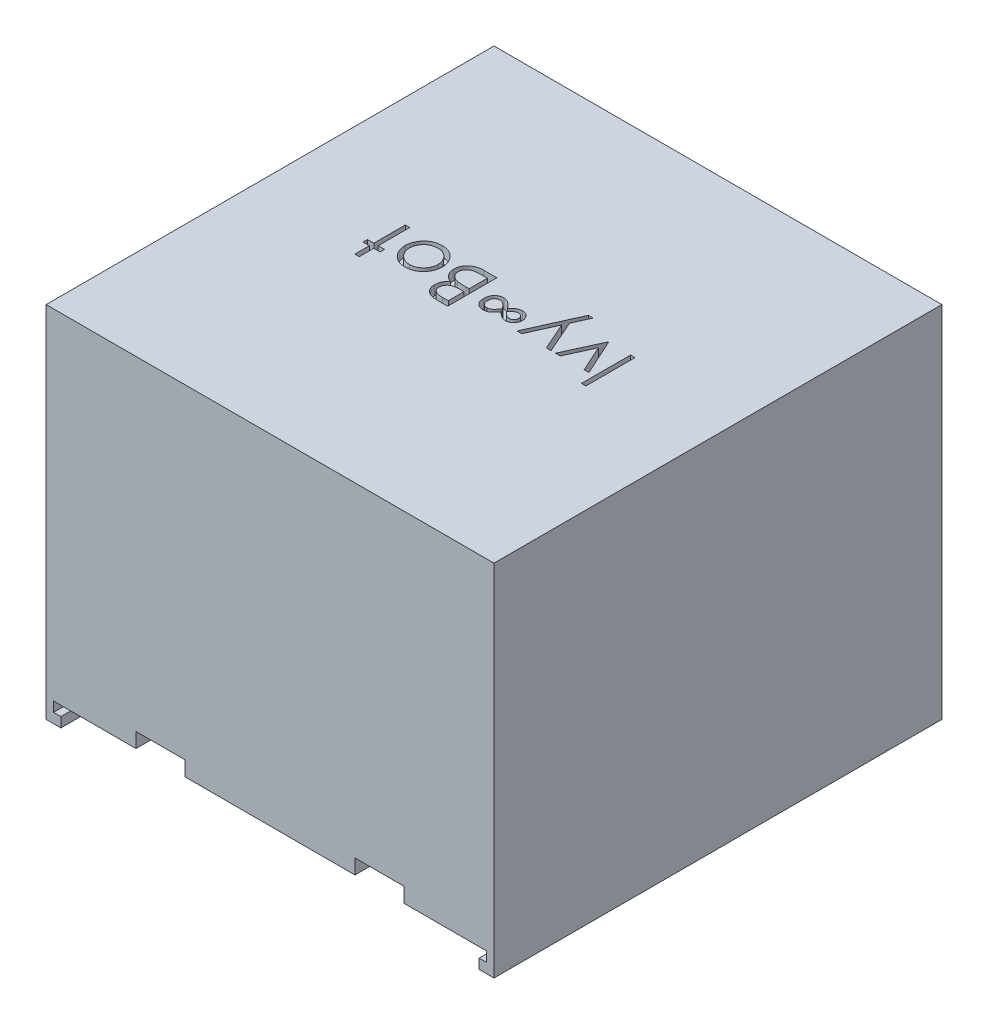
from build123d import *

# Parameters (mm, degrees)
SKETCH1_W           = 91
SKETCH1_H           = 91
SKETCH1_W_2         = 85
SKETCH1_H_2         = 85
BOSS_EXTRUDE1_DEPTH = 70
SKETCH2_W           = 91
SKETCH2_H           = 91
BOSS_EXTRUDE2_DEPTH = 3
SKETCH4_W           = 88
SKETCH4_H           = 2
CUT_EXTRUDE1_DEPTH  = 89
CUT_EXTRUDE2_REACH  = 93
SKETCH5_W           = 85
SKETCH5_H           = 2
CUT_EXTRUDE3_REACH  = 93
SKETCH6_R           = 7.5
SKETCH6_R_2         = 4
CUT_EXTRUDE4_REACH  = 93
SKETCH7_W           = 10
SKETCH7_H           = 3
SKETCH8_W           = 0.897435898
SKETCH8_H           = 10
CUT_EXTRUDE5_DEPTH  = 2


with BuildPart() as part:
    # Sketch1 → Boss-Extrude1 (new body)
    with BuildSketch(Plane(origin=(0, 0, 0), x_dir=(1, 0, 0), z_dir=(0, 1, 0))):
        Rectangle(SKETCH1_W, SKETCH1_H)
        Rectangle(SKETCH1_W_2, SKETCH1_H_2, mode=Mode.SUBTRACT)
    extrude(amount=BOSS_EXTRUDE1_DEPTH)

    # Sketch2 → Boss-Extrude2 (add)
    with BuildSketch(Plane(origin=(0, 70, 0), x_dir=(1, 0, 0), z_dir=(0, 1, 0))):
        Rectangle(SKETCH2_W, SKETCH2_H)
    extrude(amount=BOSS_EXTRUDE2_DEPTH)

    # Sketch4 → Cut-Extrude1 (cut)
    with BuildSketch(Plane.XY.offset(45.5)):
        with Locations((0, 3)):
            Rectangle(SKETCH4_W, SKETCH4_H)
    extrude(amount=-CUT_EXTRUDE1_DEPTH, mode=Mode.SUBTRACT)

    # Sketch5 → Cut-Extrude2 (cut, up to next)
    with BuildSketch(Plane.XY.offset(45.5), mode=Mode.PRIVATE) as cut_extrude2_sk1:
        with Locations((0, 1)):
            Rectangle(SKETCH5_W, SKETCH5_H)
    cut_extrude2_tool1 = extrude(cut_extrude2_sk1.sketch, amount=-CUT_EXTRUDE2_REACH, mode=Mode.PRIVATE) & part.part
    add(cut_extrude2_tool1.solids().sort_by_distance((0, 1, 45.5))[0], mode=Mode.SUBTRACT)

    # Sketch6 → Cut-Extrude3 (cut, up to next)
    with BuildSketch(Plane(origin=(0, 0, -45.5), x_dir=(-1, 0, 0), z_dir=(0, 0, -1)), mode=Mode.PRIVATE) as cut_extrude3_sk1:
        with Locations((-20, 55)):
            Circle(SKETCH6_R)
    cut_extrude3_tool1 = extrude(cut_extrude3_sk1.sketch, amount=-CUT_EXTRUDE3_REACH, mode=Mode.PRIVATE) & part.part
    add(cut_extrude3_tool1.solids().sort_by_distance((20, 55, -45.5))[0], mode=Mode.SUBTRACT)
    # Sketch6 → Cut-Extrude3 (cut, up to next)
    with BuildSketch(Plane(origin=(0, 0, -45.5), x_dir=(-1, 0, 0), z_dir=(0, 0, -1)), mode=Mode.PRIVATE) as cut_extrude3_sk2:
        with Locations((20, 55)):
            Circle(SKETCH6_R)
    cut_extrude3_tool2 = extrude(cut_extrude3_sk2.sketch, amount=-CUT_EXTRUDE3_REACH, mode=Mode.PRIVATE) & part.part
    add(cut_extrude3_tool2.solids().sort_by_distance((-20, 55, -45.5))[0], mode=Mode.SUBTRACT)
    # Sketch6 → Cut-Extrude3 (cut, up to next)
    with BuildSketch(Plane(origin=(0, 0, -45.5), x_dir=(-1, 0, 0), z_dir=(0, 0, -1)), mode=Mode.PRIVATE) as cut_extrude3_sk3:
        with Locations((0, 35.36000647)):
            Circle(SKETCH6_R_2)
    cut_extrude3_tool3 = extrude(cut_extrude3_sk3.sketch, amount=-CUT_EXTRUDE3_REACH, mode=Mode.PRIVATE) & part.part
    add(cut_extrude3_tool3.solids().sort_by_distance((0, 35.360006, -45.5))[0], mode=Mode.SUBTRACT)
    # Sketch6 → Cut-Extrude3 (cut, up to next)
    with BuildSketch(Plane(origin=(0, 0, -45.5), x_dir=(-1, 0, 0), z_dir=(0, 0, -1)), mode=Mode.PRIVATE) as cut_extrude3_sk4:
        with BuildLine():
            Line((-28.030431334, 21.464466094), (-24.494897428, 25))
            ThreePointArc((-24.494897428, 25), (0, 15), (24.494897428, 25))
            Line((24.494897428, 25), (28.030431334, 21.464466094))
            ThreePointArc((28.030431334, 21.464466094), (0, 10.0002278), (-28.030431334, 21.464466094))
        make_face()
    cut_extrude3_tool4 = extrude(cut_extrude3_sk4.sketch, amount=-CUT_EXTRUDE3_REACH, mode=Mode.PRIVATE) & part.part
    add(cut_extrude3_tool4.solids().sort_by_distance((0, 10.580556, -45.5))[0], mode=Mode.SUBTRACT)

    # Sketch7 → Cut-Extrude4 (cut, up to next)
    with BuildSketch(Plane.XY.offset(45.5), mode=Mode.PRIVATE) as cut_extrude4_sk1:
        with Locations((-22.25, 5.5)):
            Rectangle(SKETCH7_W, SKETCH7_H)
    cut_extrude4_tool1 = extrude(cut_extrude4_sk1.sketch, amount=-CUT_EXTRUDE4_REACH, mode=Mode.PRIVATE) & part.part
    add(cut_extrude4_tool1.solids().sort_by_distance((-22.25, 5.5, 45.5))[0], mode=Mode.SUBTRACT)
    # Sketch7 → Cut-Extrude4 (cut, up to next)
    with BuildSketch(Plane.XY.offset(45.5), mode=Mode.PRIVATE) as cut_extrude4_sk2:
        with Locations((22.25, 5.5)):
            Rectangle(SKETCH7_W, SKETCH7_H)
    cut_extrude4_tool2 = extrude(cut_extrude4_sk2.sketch, amount=-CUT_EXTRUDE4_REACH, mode=Mode.PRIVATE) & part.part
    add(cut_extrude4_tool2.solids().sort_by_distance((22.25, 5.5, 45.5))[0], mode=Mode.SUBTRACT)

    # Sketch8 → Cut-Extrude5 (cut)
    with BuildSketch(Plane(origin=(0, 73, 0), x_dir=(1, 0, 0), z_dir=(0, 1, 0))):
        with Locations((23.205128205, 0)):
            Rectangle(SKETCH8_W, SKETCH8_H)
        Polygon((21.602564103, -2.307692308), (20.631009615, -2.307692308), (18.205128205, 3.012820513), (15.779246795, -2.307692308), (14.807692308, -2.307692308), (18.141025641, 5), (18.269230769, 5), align=None)
        Polygon((13.91025641, -2.307692308), (12.942708333, -2.307692308), (10.46875, 3.289262821), (7.956730769, -2.307692308), (6.987179487, -2.307692308), (11.474358974, 7.692307692), (12.443910256, 7.692307692), (10.955528846, 4.377003205), align=None)
        with BuildLine():
            add(Edge.make_bspline(
                [(2.051282051, -0.584935897), (1.98830835, -0.658794194), (1.866753101, -0.801359479), (1.684132594, -1.000268264), (1.514195255, -1.182236568), (1.352863496, -1.341667376), (1.201218288, -1.480534113), (1.062469622, -1.60233963), (0.930070979, -1.69977361), (0.771152892, -1.804400749), (0.572844102, -1.903612066), (0.328255764, -1.987791738), (0.075936577, -2.04332876), (-0.095865091, -2.048620159), (-0.182291667, -2.051282051)],
                knots=[0, 0, 0, 0, 0.000291155, 0.000562003, 0.000809988, 0.001038045, 0.001242195, 0.001426882, 0.001591547, 0.001734899, 0.001997388, 0.002253962, 0.002509722, 0.002768632, 0.002768632, 0.002768632, 0.002768632], degree=3))
            add(Edge.make_bspline(
                [(-0.182291667, -2.051282051), (-0.243152307, -2.049835935), (-0.364016665, -2.046964064), (-0.542672163, -2.021052761), (-0.71784641, -1.985010765), (-0.887018916, -1.926316971), (-1.053427845, -1.857576603), (-1.214368272, -1.770810488), (-1.369456252, -1.666787196), (-1.520781863, -1.550683787), (-1.66244137, -1.417735965), (-1.782652025, -1.2623774), (-1.888234506, -1.092960237), (-1.969249735, -0.902977772), (-2.036650008, -0.698305423), (-2.081116058, -0.474297776), (-2.109678722, -0.233779549), (-2.113445905, -0.067528908), (-2.115384615, 0.018028846)],
                knots=[0, 0, 0, 0, 0.000182468, 0.000362366, 0.000540753, 0.000718124, 0.000898568, 0.001080507, 0.001265519, 0.001458254, 0.001652359, 0.001846329, 0.002045937, 0.002249536, 0.00246429, 0.002691369, 0.002933384, 0.00318999, 0.00318999, 0.00318999, 0.00318999], degree=3))
            add(Edge.make_bspline(
                [(-2.115384615, 0.018028846), (-2.114308996, 0.105590752), (-2.112217397, 0.275859566), (-2.082831403, 0.522233888), (-2.039355101, 0.751364228), (-1.980350518, 0.964323556), (-1.898970423, 1.158916949), (-1.803588711, 1.338708134), (-1.688732435, 1.500642532), (-1.55518435, 1.64224097), (-1.410817478, 1.768939821), (-1.257285206, 1.878126215), (-1.096802549, 1.972283121), (-0.928939044, 2.048097837), (-0.752313337, 2.106903264), (-0.56902133, 2.147780894), (-0.378125325, 2.175812247), (-0.248502, 2.178244704), (-0.182291667, 2.179487179)],
                knots=[0, 0, 0, 0, 0.000262542, 0.000510527, 0.000743106, 0.00096186, 0.001172043, 0.001374605, 0.001571378, 0.001765565, 0.001957215, 0.002146769, 0.002329895, 0.002514582, 0.002698288, 0.002887323, 0.003077416, 0.003275896, 0.003275896, 0.003275896, 0.003275896], degree=3))
            add(Edge.make_bspline(
                [(-0.182291667, 2.179487179), (-0.087164871, 2.175631885), (0.100233955, 2.168036995), (0.373030888, 2.108002162), (0.63139612, 2.011306023), (0.833764305, 1.8956204), (0.992602739, 1.780609394), (1.120720805, 1.678062193), (1.25737864, 1.559478289), (1.401566003, 1.422969715), (1.552262863, 1.268444736), (1.713941348, 1.100715291), (1.879873502, 0.912786764), (1.992686874, 0.781388949), (2.051282051, 0.713141026)],
                knots=[0, 0, 0, 0, 0.00028516, 0.000561762, 0.000833733, 0.00111003, 0.001257901, 0.001421834, 0.001602178, 0.001800566, 0.002017292, 0.002249664, 0.002499367, 0.002769228, 0.002769228, 0.002769228, 0.002769228], degree=3))
            add(Edge.make_bspline(
                [(2.051282051, 0.713141026), (2.127850606, 0.799459794), (2.275975541, 0.966446909), (2.516835956, 1.184562417), (2.75689525, 1.373446598), (3.002529779, 1.526895807), (3.252267932, 1.646973003), (3.50686244, 1.730795924), (3.764269409, 1.786579148), (3.938020345, 1.792117284), (4.024439103, 1.794871795)],
                knots=[0, 0, 0, 0, 0.000345911, 0.000669179, 0.000973304, 0.001261236, 0.001536318, 0.001802375, 0.002064021, 0.002322931, 0.002322931, 0.002322931, 0.002322931], degree=3))
            add(Edge.make_bspline(
                [(4.024439103, 1.794871795), (4.081297415, 1.793408479), (4.194191452, 1.790503018), (4.359610994, 1.765049092), (4.519632619, 1.72880851), (4.670756144, 1.670077531), (4.817507557, 1.601436238), (4.956598078, 1.513743271), (5.089469923, 1.411156285), (5.213813355, 1.293458977), (5.330026141, 1.166852623), (5.430998221, 1.029942981), (5.514436849, 0.884749451), (5.586384246, 0.734919621), (5.636954319, 0.575942973), (5.678821185, 0.412524053), (5.700013151, 0.240267333), (5.703401342, 0.123576516), (5.705128205, 0.064102564)],
                knots=[0, 0, 0, 0, 0.000170461, 0.000338456, 0.000501221, 0.00066159, 0.000823764, 0.000986628, 0.001153713, 0.001326616, 0.001499635, 0.001668713, 0.00183569, 0.002001485, 0.002166187, 0.002335265, 0.002506957, 0.002685422, 0.002685422, 0.002685422, 0.002685422], degree=3))
            add(Edge.make_bspline(
                [(5.705128205, 0.064102564), (5.703401342, 0.004628613), (5.700013151, -0.112062205), (5.678821185, -0.284318925), (5.636954319, -0.447737845), (5.586384246, -0.606714493), (5.514436849, -0.756544323), (5.430998221, -0.901737853), (5.330026141, -1.038647494), (5.213813355, -1.165253849), (5.089469923, -1.282951157), (4.956598078, -1.385538143), (4.817507557, -1.47323111), (4.670756144, -1.541872402), (4.519632619, -1.600603382), (4.359610994, -1.636843964), (4.194191452, -1.66229789), (4.081297415, -1.665203351), (4.024439103, -1.666666667)],
                knots=[0, 0, 0, 0, 0.000178465, 0.000350158, 0.000519236, 0.000683938, 0.000849732, 0.001016709, 0.001185787, 0.001358806, 0.00153171, 0.001698794, 0.001861659, 0.002023832, 0.002184201, 0.002346967, 0.002514961, 0.002685422, 0.002685422, 0.002685422, 0.002685422], degree=3))
            add(Edge.make_bspline(
                [(4.024439103, -1.666666667), (3.938020345, -1.663912156), (3.764269409, -1.65837402), (3.50686244, -1.602590796), (3.252267932, -1.518767874), (3.002529779, -1.398690679), (2.75689525, -1.24524147), (2.516835956, -1.056357289), (2.275975541, -0.838241781), (2.127850606, -0.671254666), (2.051282051, -0.584935897)],
                knots=[0, 0, 0, 0, 0.00025891, 0.000520556, 0.000786613, 0.001061695, 0.001349628, 0.001653752, 0.00197702, 0.002322931, 0.002322931, 0.002322931, 0.002322931], degree=3))
        make_face()
        with BuildLine():
            add(Edge.make_bspline(
                [(1.602564103, 0.058092949), (1.556805285, 0.121760724), (1.467942014, 0.245403053), (1.333418297, 0.421525264), (1.204103969, 0.584528486), (1.075354529, 0.731233041), (0.94915494, 0.862982983), (0.827671661, 0.982258006), (0.707255828, 1.084590514), (0.625981864, 1.144904362), (0.586939103, 1.173878205)],
                knots=[0, 0, 0, 0, 0.000235204, 0.000456764, 0.000664808, 0.000859284, 0.00104206, 0.001212061, 0.001369806, 0.001515642, 0.001515642, 0.001515642, 0.001515642], degree=3))
            add(Edge.make_bspline(
                [(0.586939103, 1.173878205), (0.530534227, 1.210464428), (0.420033518, 1.282139147), (0.237236489, 1.357222095), (0.046326146, 1.402642102), (-0.08455428, 1.407711957), (-0.150240385, 1.41025641)],
                knots=[0, 0, 0, 0, 0.00020132, 0.000394398, 0.000589739, 0.000786553, 0.000786553, 0.000786553, 0.000786553], degree=3))
            add(Edge.make_bspline(
                [(-0.150240385, 1.41025641), (-0.232869661, 1.406362359), (-0.393624785, 1.398786488), (-0.623539026, 1.329469178), (-0.831553215, 1.218098393), (-1.013353473, 1.061716908), (-1.162596609, 0.866440871), (-1.270700357, 0.632937936), (-1.334434212, 0.365265459), (-1.342133666, 0.175306593), (-1.346153846, 0.076121795)],
                knots=[0, 0, 0, 0, 0.000247378, 0.000481273, 0.000713411, 0.000950679, 0.001195078, 0.001445102, 0.001717184, 0.002014476, 0.002014476, 0.002014476, 0.002014476], degree=3))
            add(Edge.make_bspline(
                [(-1.346153846, 0.076121795), (-1.342355374, -0.027109416), (-1.335167435, -0.222456258), (-1.269904666, -0.497770337), (-1.162878243, -0.737404), (-1.006819012, -0.934364173), (-0.819559025, -1.089430017), (-0.606892333, -1.201847856), (-0.3714308, -1.270469177), (-0.206798635, -1.278119727), (-0.122195513, -1.282051282)],
                knots=[0, 0, 0, 0, 0.00030928, 0.000585257, 0.000843391, 0.001090241, 0.001332106, 0.001567779, 0.001807445, 0.002060809, 0.002060809, 0.002060809, 0.002060809], degree=3))
            add(Edge.make_bspline(
                [(-0.122195513, -1.282051282), (-0.063144505, -1.279518615), (0.055934496, -1.27441138), (0.231132673, -1.227051996), (0.404511391, -1.155894814), (0.547610718, -1.072334469), (0.664916451, -0.981884238), (0.768031186, -0.895944019), (0.879756315, -0.786213668), (1.00266545, -0.656661961), (1.137946978, -0.507350209), (1.283392136, -0.337551922), (1.439577929, -0.146596281), (1.546634433, -0.012147372), (1.602564103, 0.058092949)],
                knots=[0, 0, 0, 0, 0.000176839, 0.000356604, 0.000540746, 0.000738293, 0.000851274, 0.000984905, 0.001140743, 0.001320686, 0.001520656, 0.001745104, 0.001991336, 0.002260698, 0.002260698, 0.002260698, 0.002260698], degree=3))
        make_face(mode=Mode.SUBTRACT)
        with BuildLine():
            add(Edge.make_bspline(
                [(2.5, 0.064102564), (2.583070109, -0.027720398), (2.737121631, -0.198003873), (2.965212908, -0.418933875), (3.167342224, -0.590375012), (3.350360922, -0.714707933), (3.522488033, -0.796644518), (3.687002516, -0.854066373), (3.84931345, -0.889602713), (3.957503058, -0.894863124), (4.010416667, -0.897435897)],
                knots=[0, 0, 0, 0, 0.000371388, 0.00068873, 0.000951883, 0.001165785, 0.001350352, 0.001522033, 0.001687828, 0.001846537, 0.001846537, 0.001846537, 0.001846537], degree=3))
            add(Edge.make_bspline(
                [(4.010416667, -0.897435897), (4.075538898, -0.894693336), (4.201046404, -0.889407707), (4.380028756, -0.838989721), (4.541042153, -0.758705709), (4.680308821, -0.644525661), (4.796039823, -0.503823201), (4.878993176, -0.336094654), (4.927684925, -0.145602724), (4.933085709, -0.011646563), (4.935897436, 0.058092949)],
                knots=[0, 0, 0, 0, 0.000194971, 0.000375759, 0.000553142, 0.000731157, 0.00091199, 0.001095641, 0.001288043, 0.001496992, 0.001496992, 0.001496992, 0.001496992], degree=3))
            add(Edge.make_bspline(
                [(4.935897436, 0.058092949), (4.933457264, 0.127267272), (4.928736217, 0.261100165), (4.874235179, 0.45009853), (4.789412463, 0.620042627), (4.668156553, 0.762129061), (4.525548148, 0.880252894), (4.363171165, 0.965014838), (4.184586686, 1.017697323), (4.060199336, 1.022947779), (3.996394231, 1.025641026)],
                knots=[0, 0, 0, 0, 0.000206952, 0.000400393, 0.000584949, 0.000772695, 0.000956347, 0.001137346, 0.001318678, 0.001509656, 0.001509656, 0.001509656, 0.001509656], degree=3))
            add(Edge.make_bspline(
                [(3.996394231, 1.025641026), (3.937984166, 1.023155405), (3.818057042, 1.018051947), (3.638598682, 0.967301003), (3.454046654, 0.89346938), (3.268693826, 0.784931695), (3.078279442, 0.6496272), (2.887703195, 0.481437555), (2.689400432, 0.287484396), (2.564911528, 0.140660235), (2.5, 0.064102564)],
                knots=[0, 0, 0, 0, 0.000174842, 0.000358984, 0.000555768, 0.000770195, 0.001001433, 0.001255651, 0.001531868, 0.001832816, 0.001832816, 0.001832816, 0.001832816], degree=3))
        make_face(mode=Mode.SUBTRACT)
        with BuildLine():
            Line((-4.423076923, -5), (-6.374198718, -5))
            add(Edge.make_bspline(
                [(-6.374198718, -5), (-6.469710162, -4.999505761), (-6.654835111, -4.998547803), (-6.924013046, -4.983345709), (-7.176223417, -4.963135962), (-7.411020538, -4.929235199), (-7.629932198, -4.89408458), (-7.830735984, -4.842491886), (-8.015113878, -4.785505875), (-8.236513989, -4.697825165), (-8.487722752, -4.561655916), (-8.757725168, -4.35970398), (-8.992427743, -4.117579916), (-9.191994501, -3.841660448), (-9.35215107, -3.538117765), (-9.466551454, -3.213482687), (-9.540046618, -2.873216811), (-9.547510118, -2.639933092), (-9.551282051, -2.522035256)],
                knots=[0, 0, 0, 0, 0.000286486, 0.000555282, 0.000808646, 0.001045202, 0.001266844, 0.00147333, 0.001666564, 0.001845489, 0.002186981, 0.002520315, 0.002853215, 0.003194607, 0.003538692, 0.003878936, 0.004224662, 0.004577914, 0.004577914, 0.004577914, 0.004577914], degree=3))
            add(Edge.make_bspline(
                [(-9.551282051, -2.522035256), (-9.548201083, -2.41158528), (-9.542146691, -2.194540659), (-9.483000171, -1.878152008), (-9.393719933, -1.576029207), (-9.264883129, -1.291083803), (-9.100605376, -1.025819603), (-8.900736805, -0.78476134), (-8.663747458, -0.572641775), (-8.485814548, -0.45459422), (-8.395432692, -0.39463141)],
                knots=[0, 0, 0, 0, 0.00033102, 0.000650486, 0.000962279, 0.00127429, 0.001585581, 0.00189567, 0.002210588, 0.002535688, 0.002535688, 0.002535688, 0.002535688], degree=3))
            add(Edge.make_bspline(
                [(-8.395432692, -0.39463141), (-8.509041976, -0.351036683), (-8.726404679, -0.267629169), (-9.025910911, -0.119594521), (-9.28404291, 0.040181665), (-9.504127292, 0.212870501), (-9.688542454, 0.404110766), (-9.852826885, 0.608866021), (-9.992250031, 0.834267194), (-10.111209082, 1.07542995), (-10.205443552, 1.331077181), (-10.270855378, 1.599296342), (-10.312339767, 1.877049479), (-10.317764606, 2.065824994), (-10.320512821, 2.161458333)],
                knots=[0, 0, 0, 0, 0.000364919, 0.00069818, 0.001000551, 0.001274295, 0.001534943, 0.00179586, 0.002060435, 0.002328303, 0.002601452, 0.002875957, 0.003155288, 0.003442089, 0.003442089, 0.003442089, 0.003442089], degree=3))
            add(Edge.make_bspline(
                [(-10.320512821, 2.161458333), (-10.317721564, 2.259077806), (-10.312229689, 2.451146852), (-10.27171931, 2.733306699), (-10.203107799, 3.002940879), (-10.108670548, 3.261844192), (-9.985566837, 3.508500317), (-9.83684476, 3.744847698), (-9.658346901, 3.96738363), (-9.457340756, 4.179337386), (-9.233075727, 4.373159938), (-8.985953212, 4.539724667), (-8.722306704, 4.68359347), (-8.438525877, 4.799255919), (-8.136624352, 4.88979846), (-7.816531402, 4.952399423), (-7.47842879, 4.994749369), (-7.246397561, 4.998220092), (-7.127403846, 5)],
                knots=[0, 0, 0, 0, 0.000292804, 0.0005761, 0.000853035, 0.001126185, 0.001401215, 0.001678534, 0.00196229, 0.002255587, 0.00255391, 0.002849497, 0.003147981, 0.003453396, 0.003767107, 0.004092003, 0.004430918, 0.004787691, 0.004787691, 0.004787691, 0.004787691], degree=3))
            Line((-7.127403846, 5), (-4.423076923, 5))
            Line((-4.423076923, 5), (-4.423076923, -5))
        make_face()
        with BuildLine():
            Line((-5.320512821, -3.974358974), (-5.320512821, -0.769230769))
            Line((-5.320512821, -0.769230769), (-5.923477564, -0.769230769))
            add(Edge.make_bspline(
                [(-5.923477564, -0.769230769), (-6.011617773, -0.770363898), (-6.181922619, -0.772553333), (-6.429206306, -0.779022702), (-6.658170082, -0.796343945), (-6.869602868, -0.814664049), (-7.06208771, -0.842873141), (-7.236268465, -0.877393512), (-7.393711546, -0.913581653), (-7.57519007, -0.975303019), (-7.781017835, -1.065565887), (-7.998899793, -1.209076735), (-8.195003349, -1.375231272), (-8.356777465, -1.572316517), (-8.491460288, -1.785150757), (-8.582137003, -2.015321105), (-8.64536018, -2.254895828), (-8.65098852, -2.420118948), (-8.653846154, -2.50400641)],
                knots=[0, 0, 0, 0, 0.000264453, 0.000510978, 0.000741903, 0.000953192, 0.001147533, 0.001325108, 0.001485927, 0.001631625, 0.001899703, 0.002157518, 0.002411736, 0.002667707, 0.002919546, 0.003163945, 0.003407357, 0.003658406, 0.003658406, 0.003658406, 0.003658406], degree=3))
            add(Edge.make_bspline(
                [(-8.653846154, -2.50400641), (-8.65245244, -2.559541741), (-8.649718518, -2.668480358), (-8.623944753, -2.827197666), (-8.588377264, -2.978233817), (-8.529717616, -3.117517147), (-8.460221095, -3.249938462), (-8.371143154, -3.371314825), (-8.268428094, -3.484934336), (-8.148675206, -3.58775153), (-8.012374018, -3.680743748), (-7.855206829, -3.758155329), (-7.681446632, -3.826950057), (-7.487469984, -3.879098073), (-7.277140723, -3.924370851), (-7.047249972, -3.952919615), (-6.799183209, -3.971259791), (-6.627307208, -3.973302871), (-6.538461538, -3.974358974)],
                knots=[0, 0, 0, 0, 0.000166459, 0.000326527, 0.000481514, 0.000630682, 0.000778567, 0.000929234, 0.001080963, 0.001237187, 0.001401645, 0.001574549, 0.001761664, 0.001961432, 0.002176336, 0.00240667, 0.002655721, 0.002922215, 0.002922215, 0.002922215, 0.002922215], degree=3))
            Line((-6.538461538, -3.974358974), (-5.320512821, -3.974358974))
        make_face(mode=Mode.SUBTRACT)
        with BuildLine():
            Line((-5.320512821, 0.256410256), (-5.320512821, 3.974358974))
            Line((-5.320512821, 3.974358974), (-6.598557692, 3.974358974))
            add(Edge.make_bspline(
                [(-6.598557692, 3.974358974), (-6.690031193, 3.973157124), (-6.866334305, 3.970840717), (-7.121079364, 3.965344201), (-7.355934813, 3.944952145), (-7.572856066, 3.925401501), (-7.770839451, 3.893461464), (-7.951810696, 3.862532486), (-8.111636331, 3.817018967), (-8.298641555, 3.75439156), (-8.507805018, 3.654304661), (-8.736221388, 3.507118305), (-8.937408697, 3.327834476), (-9.108102031, 3.121399324), (-9.250026055, 2.899257825), (-9.348209451, 2.660972765), (-9.411826701, 2.414503254), (-9.4193193, 2.245976442), (-9.423076923, 2.161458333)],
                knots=[0, 0, 0, 0, 0.000274468, 0.000529002, 0.000764069, 0.000981534, 0.001182115, 0.001365592, 0.001531797, 0.001680035, 0.001956926, 0.002224735, 0.002492903, 0.002761698, 0.003026273, 0.003280372, 0.003532044, 0.003785241, 0.003785241, 0.003785241, 0.003785241], degree=3))
            add(Edge.make_bspline(
                [(-9.423076923, 2.161458333), (-9.422309877, 2.108612292), (-9.420788157, 2.003772622), (-9.396868238, 1.849842965), (-9.363673509, 1.699996817), (-9.314753801, 1.556269584), (-9.255574257, 1.416186309), (-9.17750136, 1.284305044), (-9.08943571, 1.155011811), (-8.953035338, 0.989631452), (-8.75193439, 0.801385453), (-8.466062296, 0.619383901), (-8.142833187, 0.470227958), (-7.907846423, 0.407172288), (-7.786458333, 0.374599359)],
                knots=[0, 0, 0, 0, 0.000158367, 0.00031418, 0.000466279, 0.000618311, 0.000769032, 0.000921591, 0.001077172, 0.001237991, 0.001563978, 0.001898465, 0.002250762, 0.002627215, 0.002627215, 0.002627215, 0.002627215], degree=3))
            add(Edge.make_bspline(
                [(-7.786458333, 0.374599359), (-7.737803819, 0.364727027), (-7.632310797, 0.343321775), (-7.460288264, 0.320741097), (-7.263241541, 0.300485493), (-7.042012838, 0.2858958), (-6.795722302, 0.270234019), (-6.524449055, 0.264359896), (-6.228001318, 0.257190218), (-6.022308574, 0.256676894), (-5.915464744, 0.256410256)],
                knots=[0, 0, 0, 0, 0.000148899, 0.000322844, 0.000520177, 0.00074311, 0.000987903, 0.001260456, 0.001556992, 0.001877511, 0.001877511, 0.001877511, 0.001877511], degree=3))
            Line((-5.915464744, 0.256410256), (-5.320512821, 0.256410256))
        make_face(mode=Mode.SUBTRACT)
        with BuildLine():
            add(Edge.make_bspline(
                [(-15.645032051, -2.435897436), (-15.782153377, -2.432986315), (-16.051014787, -2.427278319), (-16.444703405, -2.365971371), (-16.820114054, -2.2730033), (-17.178857135, -2.142138645), (-17.517965118, -1.970439106), (-17.840465679, -1.762803271), (-18.145712675, -1.517826368), (-18.328627987, -1.328215923), (-18.421474359, -1.231971154)],
                knots=[0, 0, 0, 0, 0.000411053, 0.000805974, 0.001192224, 0.001569943, 0.001948893, 0.002330077, 0.002718951, 0.003119818, 0.003119818, 0.003119818, 0.003119818], degree=3))
            add(Edge.make_bspline(
                [(-18.421474359, -1.231971154), (-18.501422799, -1.139931194), (-18.659772457, -0.957632502), (-18.862817368, -0.662045037), (-19.037736111, -0.355930464), (-19.177916, -0.035223816), (-19.288444639, 0.297275244), (-19.366918057, 0.642709562), (-19.413595014, 1.000316268), (-19.419889205, 1.243184377), (-19.423076923, 1.366185897)],
                knots=[0, 0, 0, 0, 0.00036549, 0.000723907, 0.001073752, 0.001421762, 0.001772071, 0.002123416, 0.00248295, 0.002851888, 0.002851888, 0.002851888, 0.002851888], degree=3))
            add(Edge.make_bspline(
                [(-19.423076923, 1.366185897), (-19.420273102, 1.489900348), (-19.414732622, 1.734365872), (-19.362322288, 2.0944212), (-19.280804904, 2.443549275), (-19.164142492, 2.780288362), (-19.014547959, 3.105668013), (-18.832002889, 3.418266176), (-18.615227798, 3.718702957), (-18.369498381, 4.004414297), (-18.097935437, 4.267776916), (-17.80326773, 4.497175528), (-17.491072362, 4.694537008), (-17.157087557, 4.8512969), (-16.806067482, 4.97765629), (-16.435779431, 5.064789222), (-16.04655373, 5.117942675), (-15.780755284, 5.124736191), (-15.645032051, 5.128205128)],
                knots=[0, 0, 0, 0, 0.000370939, 0.000732993, 0.001089147, 0.001445177, 0.001800129, 0.002161911, 0.002529378, 0.00291005, 0.003291149, 0.003662213, 0.004028498, 0.004396767, 0.004766791, 0.005145773, 0.005535884, 0.005942934, 0.005942934, 0.005942934, 0.005942934], degree=3))
            add(Edge.make_bspline(
                [(-15.645032051, 5.128205128), (-15.508650383, 5.12470749), (-15.241539995, 5.117857188), (-14.850848696, 5.065184608), (-14.479001616, 4.976725311), (-14.126321136, 4.852861201), (-13.792337684, 4.693249431), (-13.47898953, 4.497943443), (-13.184182834, 4.267660753), (-12.91253475, 4.004445772), (-12.666828161, 3.718694848), (-12.450047179, 3.41826828), (-12.267503639, 3.105667464), (-12.117908706, 2.780288508), (-12.0012464, 2.443549236), (-11.919728988, 2.094421211), (-11.867318662, 1.73436587), (-11.86177818, 1.489900347), (-11.858974359, 1.366185897)],
                knots=[0, 0, 0, 0, 0.000409051, 0.000801148, 0.00118013, 0.00155393, 0.001920391, 0.002288376, 0.002659439, 0.003040538, 0.00342121, 0.003788677, 0.00415046, 0.004505411, 0.004861441, 0.005217595, 0.005579649, 0.005950589, 0.005950589, 0.005950589, 0.005950589], degree=3))
            add(Edge.make_bspline(
                [(-11.858974359, 1.366185897), (-11.862176192, 1.24385018), (-11.868515272, 1.001646483), (-11.915255928, 0.644751627), (-11.992875495, 0.300374539), (-12.104936377, -0.03030881), (-12.244856048, -0.350244646), (-12.41801431, -0.657481601), (-12.623023341, -0.951777473), (-12.780757813, -1.133834416), (-12.860576923, -1.225961538)],
                knots=[0, 0, 0, 0, 0.000366937, 0.000726472, 0.001077816, 0.001424324, 0.001772334, 0.002123924, 0.002480697, 0.002846187, 0.002846187, 0.002846187, 0.002846187], degree=3))
            add(Edge.make_bspline(
                [(-12.860576923, -1.225961538), (-12.953291003, -1.323024754), (-13.135629554, -1.513916646), (-13.442285613, -1.758410197), (-13.763398889, -1.968845463), (-14.104694234, -2.140458592), (-14.464434827, -2.272765856), (-14.842635604, -2.366405282), (-15.237757168, -2.427007142), (-15.507920805, -2.432904471), (-15.645032051, -2.435897436)],
                knots=[0, 0, 0, 0, 0.00040228, 0.000791155, 0.001173426, 0.001552376, 0.001934548, 0.002320798, 0.002719682, 0.003130735, 0.003130735, 0.003130735, 0.003130735], degree=3))
        make_face()
        with BuildLine():
            add(Edge.make_bspline(
                [(-15.641025641, -1.538461538), (-15.544061146, -1.535705413), (-15.352635279, -1.530264312), (-15.070863468, -1.488883876), (-14.799611685, -1.423311632), (-14.53833075, -1.330186481), (-14.288030967, -1.209793325), (-14.048437849, -1.062753788), (-13.820191603, -0.888286311), (-13.605059187, -0.689852474), (-13.405263224, -0.474337243), (-13.232766467, -0.242524791), (-13.0849898, -0.000856505), (-12.964244182, 0.252033544), (-12.871608853, 0.516840136), (-12.805973802, 0.792048174), (-12.764514833, 1.078476756), (-12.759141049, 1.273228577), (-12.756410256, 1.372195513)],
                knots=[0, 0, 0, 0, 0.000290803, 0.000574099, 0.000852494, 0.001126845, 0.001404598, 0.001684259, 0.001968721, 0.00226504, 0.002561358, 0.002849019, 0.003130389, 0.003409949, 0.003688078, 0.003970366, 0.004257629, 0.004554435, 0.004554435, 0.004554435, 0.004554435], degree=3))
            add(Edge.make_bspline(
                [(-12.756410256, 1.372195513), (-12.760989067, 1.500064098), (-12.770077149, 1.753859329), (-12.844355966, 2.127522306), (-12.967736542, 2.486923655), (-13.137870093, 2.82773609), (-13.347394678, 3.143614743), (-13.59239071, 3.427654319), (-13.876245342, 3.66890111), (-14.189292781, 3.871793724), (-14.527096745, 4.031571466), (-14.883993807, 4.146153354), (-15.256734313, 4.219635696), (-15.511807444, 4.227025573), (-15.641025641, 4.230769231)],
                knots=[0, 0, 0, 0, 0.000383367, 0.000760911, 0.001137838, 0.001520372, 0.001900395, 0.002272388, 0.002641761, 0.003014039, 0.003388595, 0.003759188, 0.004136355, 0.004523601, 0.004523601, 0.004523601, 0.004523601], degree=3))
            add(Edge.make_bspline(
                [(-15.641025641, 4.230769231), (-15.770251271, 4.227047259), (-16.025339074, 4.219700189), (-16.3985982, 4.145781068), (-16.756473403, 4.032069709), (-17.094628597, 3.871613264), (-17.407818598, 3.669667991), (-17.689646313, 3.426279958), (-17.936752218, 3.144361431), (-18.146484271, 2.828154923), (-18.313876499, 2.48639382), (-18.437837298, 2.127588528), (-18.511937974, 1.753842463), (-18.521050101, 1.500058448), (-18.525641026, 1.372195513)],
                knots=[0, 0, 0, 0, 0.000387246, 0.000764413, 0.001136912, 0.001511469, 0.001883747, 0.002251601, 0.002624913, 0.003004936, 0.003386582, 0.00376351, 0.004141054, 0.004524421, 0.004524421, 0.004524421, 0.004524421], degree=3))
            add(Edge.make_bspline(
                [(-18.525641026, 1.372195513), (-18.52293069, 1.273220622), (-18.517597164, 1.078453146), (-18.475845382, 0.79213843), (-18.411240565, 0.516292037), (-18.314611297, 0.253101533), (-18.198072432, -0.002087595), (-18.046713096, -0.241801029), (-17.875019359, -0.474484292), (-17.674857144, -0.689722644), (-17.459748876, -0.889011314), (-17.229787944, -1.062118243), (-16.990083547, -1.209877292), (-16.739704665, -1.330201309), (-16.479014996, -1.422953191), (-16.208586748, -1.489169518), (-15.928062757, -1.530113435), (-15.737316627, -1.53566104), (-15.641025641, -1.538461538)],
                knots=[0, 0, 0, 0, 0.000296806, 0.000584068, 0.000866357, 0.001145155, 0.00142386, 0.001706277, 0.001993937, 0.002290256, 0.002586574, 0.002872633, 0.003152294, 0.003430047, 0.003704398, 0.003980848, 0.004264144, 0.004552946, 0.004552946, 0.004552946, 0.004552946], degree=3))
        make_face(mode=Mode.SUBTRACT)
        Polygon((-22.115384615, -5.256410256), (-23.012820513, -5.256410256), (-23.012820513, -2.307692308), (-24.294871795, -2.307692308), (-24.294871795, -1.41025641), (-23.012820513, -1.41025641), (-23.012820513, 5), (-22.115384615, 5), (-22.115384615, -1.41025641), (-20.833333333, -1.41025641), (-20.833333333, -2.307692308), (-22.115384615, -2.307692308), align=None)
    extrude(amount=-CUT_EXTRUDE5_DEPTH, mode=Mode.SUBTRACT)


solid = part.part
